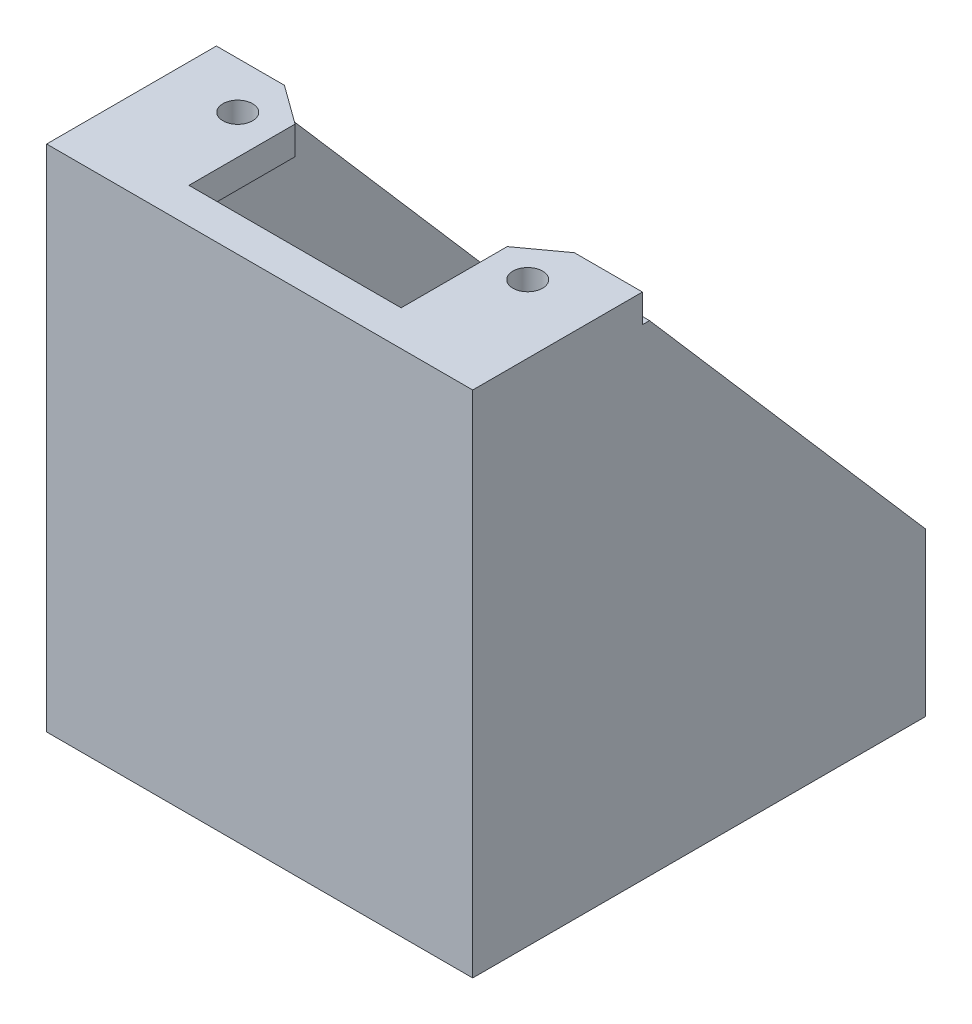
from build123d import *

# Parameters (mm, degrees)
BOSS_EXTRUDE1_DEPTH = 32.5
CUT_EXTRUDE1_DEPTH  = 31.122
SKETCH4_R           = 1.05
BOSS_EXTRUDE2_DEPTH = 1.5
SKETCH5_R           = 1.05
BOSS_EXTRUDE3_DEPTH = 2
FILLET1_R           = 1
SKETCH6_W           = 15
SKETCH6_H           = 2.5
BOSS_EXTRUDE4_DEPTH = 2


with BuildPart() as part:
    # Sketch2 → Boss-Extrude1 (new body)
    with BuildSketch(Plane(origin=(0, 0, 0), x_dir=(1, 0, 0), z_dir=(0, 1, 0))):
        Polygon((15.061, 0), (15.061, 32), (12.561, 32), (12.561, 2.5), (-12.561, 2.5), (-12.561, 32), (-15.061, 32), (-15.061, 0), align=None)
    extrude(amount=BOSS_EXTRUDE1_DEPTH)

    # Sketch3 → Cut-Extrude1 (cut, through all)
    with BuildSketch(Plane(origin=(15.061, 0, 0), x_dir=(0, 0, -1), z_dir=(1, 0, 0))):
        Polygon((32, 10), (12.5, 32.5), (32, 32.5), align=None)
    extrude(amount=-CUT_EXTRUDE1_DEPTH, mode=Mode.SUBTRACT)

    # Sketch4 → Boss-Extrude2 (add)
    with BuildSketch(Plane.XZ):
        Polygon((-15.061, 0), (-15.061, -32), (-10.061, -32), (-8.061, -29.4695), (-12.561, -25), (-12.561, -10), (-7.5, -6), (7.5, -6), (12.561, -10), (12.561, -25), (8.061, -29.4695), (10.061, -32), (15.061, -32), (15.061, 0), align=None)
        with Locations((-10.2499, -4.95)):
            Circle(SKETCH4_R, mode=Mode.SUBTRACT)
        with Locations((-10.2499, -29.4)):
            Circle(SKETCH4_R, mode=Mode.SUBTRACT)
        with Locations((10.2499, -29.4)):
            Circle(SKETCH4_R, mode=Mode.SUBTRACT)
        with Locations((10.2499, -4.95)):
            Circle(SKETCH4_R, mode=Mode.SUBTRACT)
    extrude(amount=BOSS_EXTRUDE2_DEPTH)

    # Sketch5 → Boss-Extrude3 (add)
    with BuildSketch(Plane(origin=(0, 32.5, 0), x_dir=(1, 0, 0), z_dir=(0, 1, 0))):
        Polygon((-15.061, 12), (-10.2499, 12), (-7.5, 10), (-7.5, 0), (-15.061, 0), align=None)
        with Locations((-10.2499, 8.7)):
            Circle(SKETCH5_R, mode=Mode.SUBTRACT)
        Polygon((15.061, 12), (10.2499, 12), (7.5, 10), (7.5, 0), (15.061, 0), align=None)
        with Locations((10.2499, 8.7)):
            Circle(SKETCH5_R, mode=Mode.SUBTRACT)
    extrude(amount=BOSS_EXTRUDE3_DEPTH)

    # Fillet1
    fillet1_edges = [part.edges().sort_by_distance(p)[0] for p in [
        (-8.061, -0.75, -29.4695),
        (8.061, -0.75, -29.4695),
    ]]
    fillet(fillet1_edges, radius=FILLET1_R)

    # Sketch6 → Boss-Extrude4 (add)
    with BuildSketch(Plane(origin=(0, 34.5, 0), x_dir=(1, 0, 0), z_dir=(0, 1, 0))):
        with Locations((0, 1.25)):
            Rectangle(SKETCH6_W, SKETCH6_H)
    extrude(amount=-BOSS_EXTRUDE4_DEPTH)


solid = part.part
